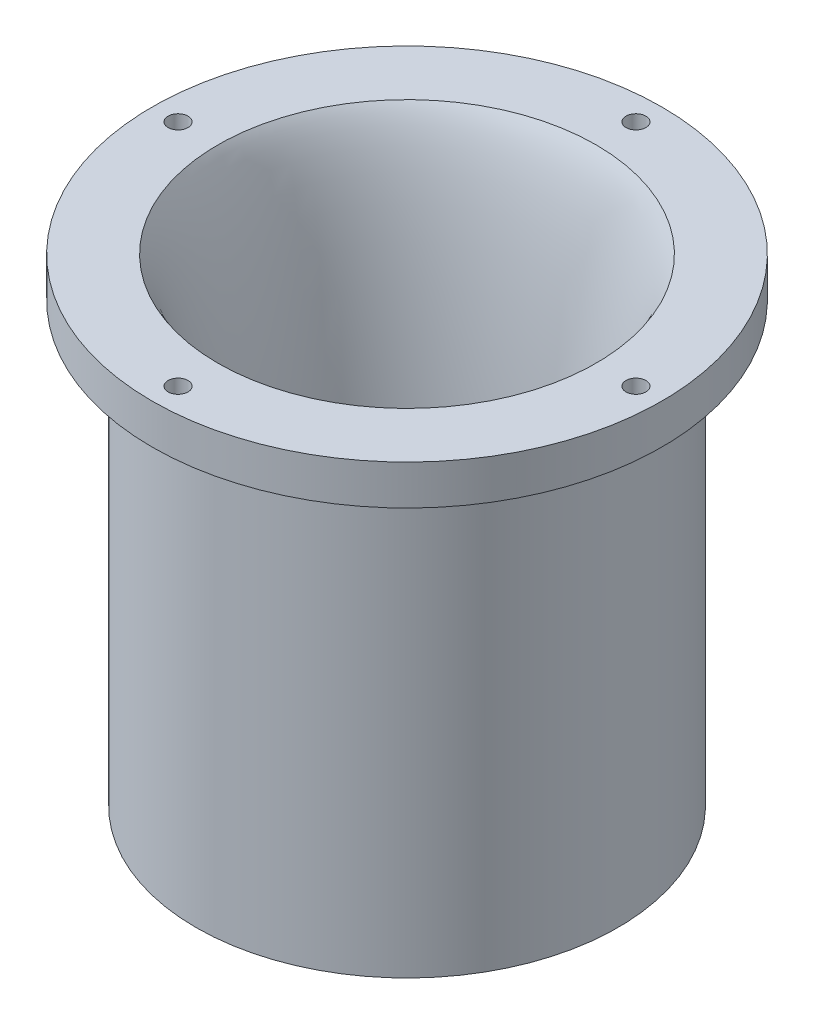
from build123d import *

# Parameters (mm, degrees)
SKETCH3_R          = 2.5
CUT_EXTRUDE1_DEPTH = 10


with BuildPart() as part:
    # Sketch1 → Revolve2 (revolve)
    with BuildSketch(Plane(origin=(0, 0, 0), x_dir=(0, 0, -1), z_dir=(1, 0, 0))):
        with BuildLine():
            Line((35, 0), (38, 0))
            Line((38, 0), (38, -20))
            Line((38, -20), (53, -20))
            Line((53, -20), (53, 90))
            Line((53, 90), (56.634888803, 90))
            Line((56.634888803, 90), (64, 90))
            Line((64, 90), (64, 100))
            Line((64, 100), (47.5, 100))
            add(Edge.make_bspline(
                [(35, 0), (35, 0.743462171), (35.036045174, 3.604263203), (34.55519496, 30.18748809), (38.452213163, 87.123824556), (47.5, 100)],
                knots=[0, 0, 0, 0, 0.040283917, 0.140283917, 1, 1, 1, 1], degree=3))
        make_face()
    revolve(axis=Axis((0, 0, 0), (0, 1, 0)))

    # Sketch3 → Cut-Extrude1 (cut)
    with BuildSketch(Plane(origin=(0, 100, 0), x_dir=(1, 0, 0), z_dir=(0, 1, 0))):
        with Locations((0, 57.5)):
            Circle(SKETCH3_R)
        with Locations((57.5, 0)):
            Circle(SKETCH3_R)
        with Locations((0, -57.5)):
            Circle(SKETCH3_R)
        with Locations((-57.5, 0)):
            Circle(SKETCH3_R)
    extrude(amount=-CUT_EXTRUDE1_DEPTH, mode=Mode.SUBTRACT)


solid = part.part
